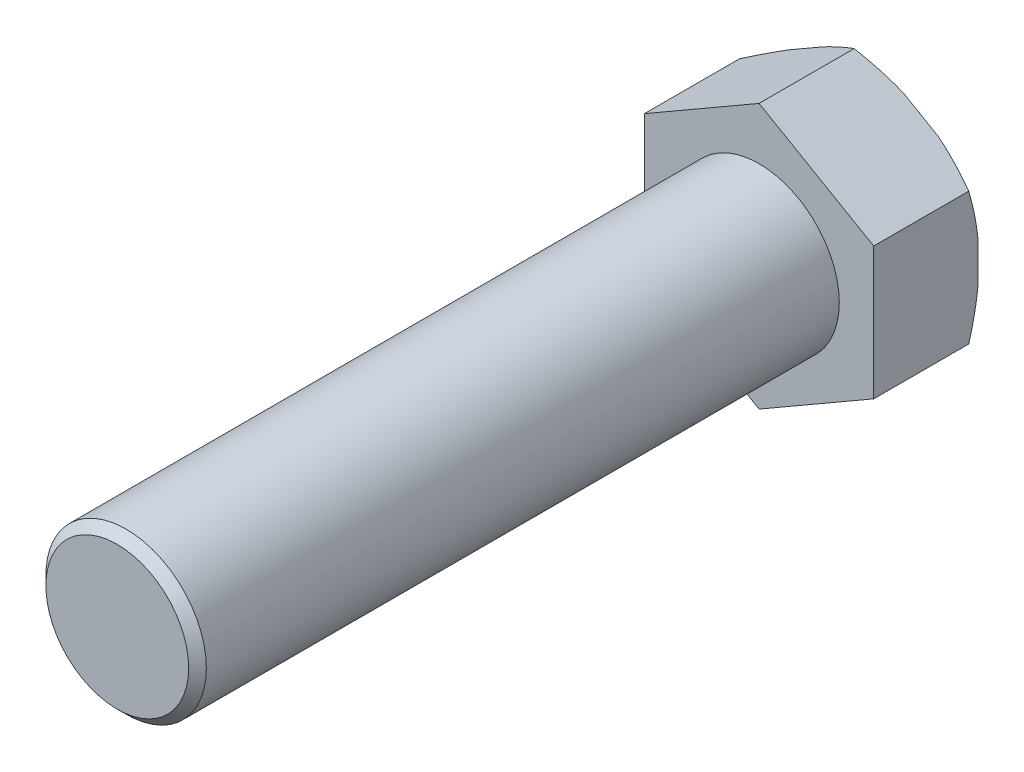
from build123d import *

# Parameters (mm, degrees)
SKETCH_1_R      = 10
EXTRUDE_1_DEPTH = 80
EXTRUDE_2_DEPTH = 13
CHAMFER_1_SIZE  = 1.1015


with BuildPart() as part:
    # Эскиз1 → Бобышка-Вытянуть1 (new body)
    with BuildSketch(Plane.XY):
        Circle(SKETCH_1_R)
    extrude(amount=EXTRUDE_1_DEPTH)

    # Фаска1
    chamfer_1_edges = [part.edges().sort_by_distance(p)[0] for p in [
        (-10, 0, 80),
    ]]
    chamfer(chamfer_1_edges, length=CHAMFER_1_SIZE)


with BuildPart() as body_2:
    # Эскиз1<4> → Бобышка-Вытянуть2 (new body)
    with BuildSketch(Plane.XY):
        Polygon((0, 16.5), (-14.289419162, 8.25), (-14.289419162, -8.25), (0, -16.5), (14.289419162, -8.25), (14.289419162, 8.25), align=None)
    extrude(amount=-EXTRUDE_2_DEPTH)

    # Эскиз3 → Вырез-Повернуть1 (revolve, cut)
    with BuildSketch(Plane(origin=(0, 0, 0), x_dir=(0, 0, -1), z_dir=(1, 0, 0))):
        Polygon((13, 24.5), (13, 14.5), (7.226497308, 24.5), align=None)
    revolve(axis=Axis((0, 0, 0), (0, 0, -1)), mode=Mode.SUBTRACT)


solid = Compound([part.part, body_2.part])
